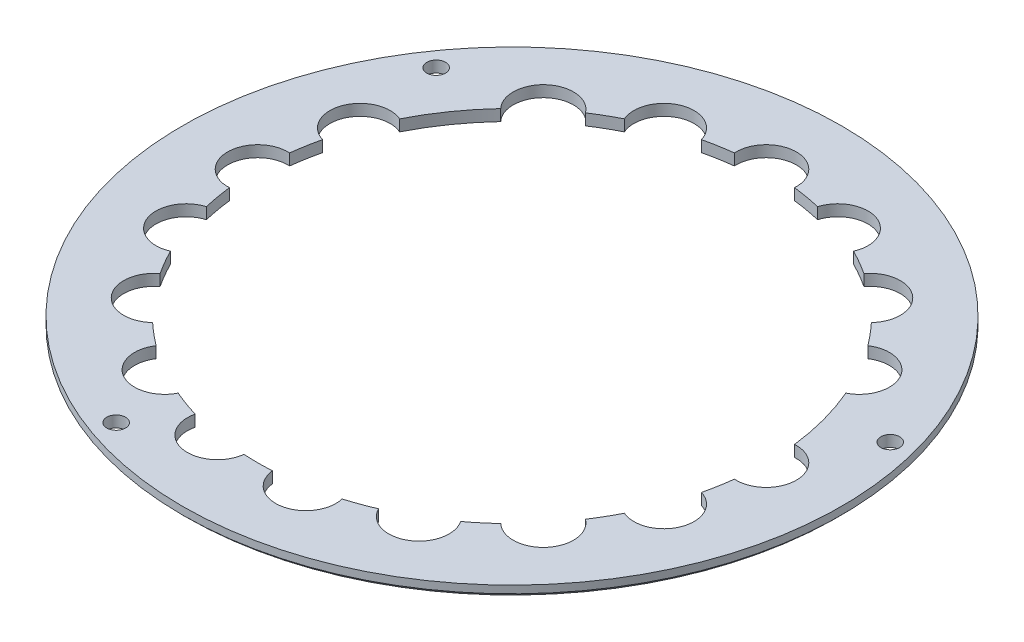
from build123d import *

# Parameters (mm, degrees)
SKETCH1_R                    = 17.5
BOSS_EXTRUDE1_DEPTH          = 0.6
CUT_EXTRUDE1_REACH           = 2.6
SKETCH2_R                    = 13.5
SKETCH3_R                    = 1.6
CUT_EXTRUDE2_DEPTH           = 0.6
CIRPATTERN1_COUNT            = 6
CIRPATTERN1_ANGLE            = 100
SKETCH4_R                    = 1.6
CUT_EXTRUDE3_DEPTH           = 0.6
CIRPATTERN2_COUNT            = 11
CIRPATTERN2_ANGLE            = 200
F_1_0_1_DIAMETER_HOLE1_D     = 1
F_1_0_1_DIAMETER_HOLE1_DEPTH = 0.6
CHAMFER1_SIZE                = 0.2


with BuildPart() as part:
    # Sketch1 → Boss-Extrude1 (new body)
    with BuildSketch(Plane(origin=(0, 0, 0), x_dir=(1, 0, 0), z_dir=(0, 1, 0))):
        Circle(SKETCH1_R)
    extrude(amount=BOSS_EXTRUDE1_DEPTH)

    # Sketch2 → Cut-Extrude1 (cut, up to next)
    with BuildSketch(Plane(origin=(0, 0.6, 0), x_dir=(1, 0, 0), z_dir=(0, 1, 0)), mode=Mode.PRIVATE) as cut_extrude1_sk1:
        Circle(SKETCH2_R)
    cut_extrude1_tool1 = extrude(cut_extrude1_sk1.sketch, amount=-CUT_EXTRUDE1_REACH, mode=Mode.PRIVATE) & part.part
    add(cut_extrude1_tool1.solids().sort_by_distance((0, 0.6, 0))[0], mode=Mode.SUBTRACT)

    # Sketch3 → Cut-Extrude2 (cut)
    with BuildSketch(Plane(origin=(0, 0.6, 0), x_dir=(1, 0, 0), z_dir=(0, 1, 0))):
        with Locations((11.691342951, 6.75)):
            Circle(SKETCH3_R)
    cut_extrude2 = extrude(amount=-CUT_EXTRUDE2_DEPTH, mode=Mode.SUBTRACT)

    # CirPattern1: Cut-Extrude2 ×6 about axis
    cirpattern1_axis = Axis((0, 0, 0), (0, 1, 0))
    for i in range(1, CIRPATTERN1_COUNT):
        add(cut_extrude2.rotate(cirpattern1_axis, i * CIRPATTERN1_ANGLE / (CIRPATTERN1_COUNT - 1)), mode=Mode.SUBTRACT)

    # Sketch4 → Cut-Extrude3 (cut)
    with BuildSketch(Plane(origin=(0, 0.6, 0), x_dir=(1, 0, 0), z_dir=(0, 1, 0))):
        with Locations((13.5, 0)):
            Circle(SKETCH4_R)
    cut_extrude3 = extrude(amount=-CUT_EXTRUDE3_DEPTH, mode=Mode.SUBTRACT)

    # CirPattern2: Cut-Extrude3 ×11 about axis
    cirpattern2_axis = Axis((0, 0, 0), (0, -1, 0))
    for i in range(1, CIRPATTERN2_COUNT):
        add(cut_extrude3.rotate(cirpattern2_axis, i * CIRPATTERN2_ANGLE / (CIRPATTERN2_COUNT - 1)), mode=Mode.SUBTRACT)

    # Ø1.0 (1) Diameter Hole1
    with Locations(Plane(origin=(0, 0.6, 0), x_dir=(1, 0, 0), z_dir=(0, 1, 0))):
        with Locations((15.841183551, 4.24463234), (-13.434093526, 9.406653556), (-5.609130351, -15.410958981)):
            Hole(F_1_0_1_DIAMETER_HOLE1_D / 2, depth=F_1_0_1_DIAMETER_HOLE1_DEPTH)

    # Chamfer1
    chamfer1_edges = [part.edges().sort_by_distance(p)[0] for p in [
        (-17.5, 0, 0),
    ]]
    chamfer(chamfer1_edges, length=CHAMFER1_SIZE)


solid = part.part
